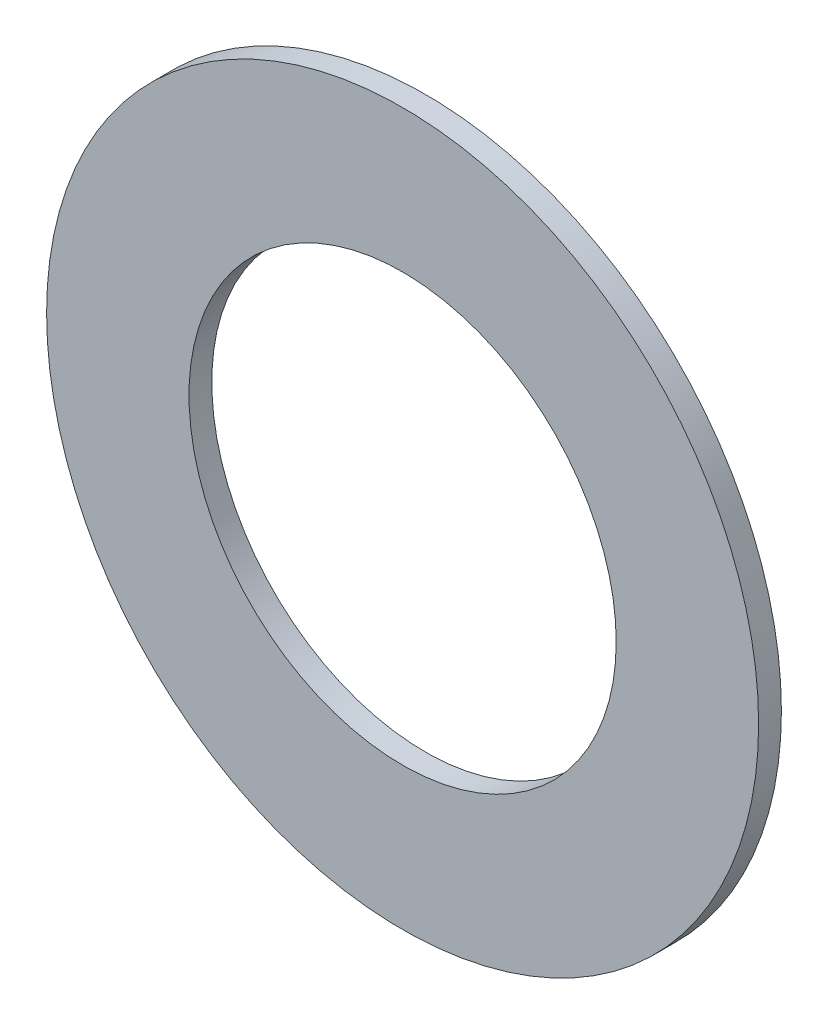
from build123d import *

# Parameters (mm, degrees)
FACE_2_R     = 7.9375
FACE_2_R_2   = 4.7625
WASHER_DEPTH = 0.508


with BuildPart() as part:
    # face 2 → washer (new body)
    with BuildSketch(Plane.XY):
        Circle(FACE_2_R)
        Circle(FACE_2_R_2, mode=Mode.SUBTRACT)
    extrude(amount=-WASHER_DEPTH)


solid = part.part
